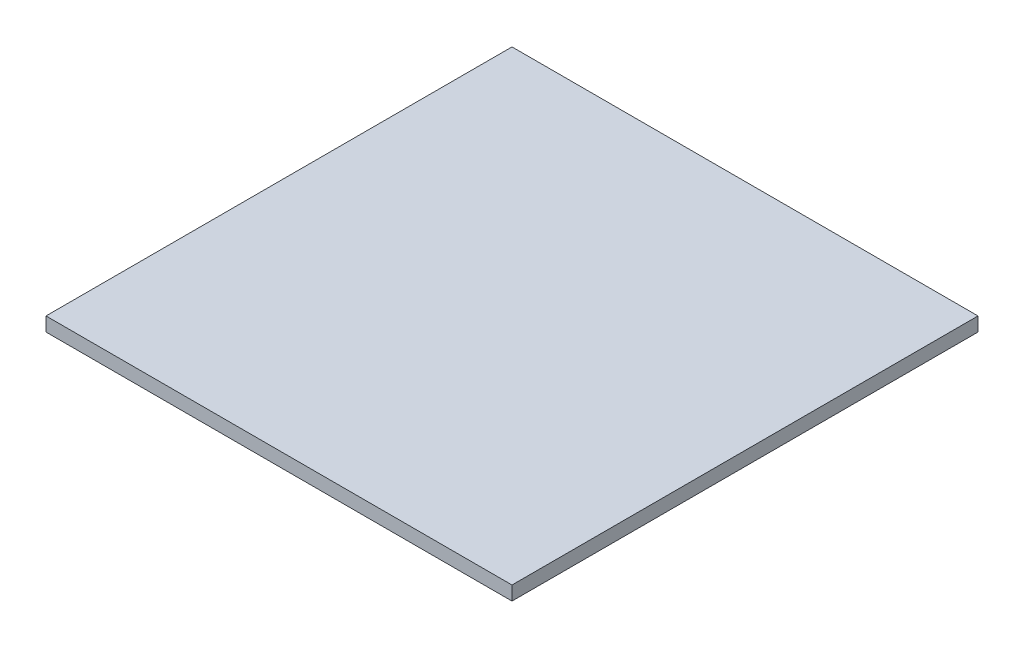
from build123d import *

# Parameters (mm, degrees)
SKETCH1_W           = 59.309
SKETCH1_H           = 59.309
BOSS_EXTRUDE1_DEPTH = 1.778


with BuildPart() as part:
    # Sketch1 → Boss-Extrude1 (new body)
    with BuildSketch(Plane(origin=(0, 0, 0), x_dir=(1, 0, 0), z_dir=(0, 1, 0))):
        Rectangle(SKETCH1_W, SKETCH1_H)
    extrude(amount=BOSS_EXTRUDE1_DEPTH)


solid = part.part
